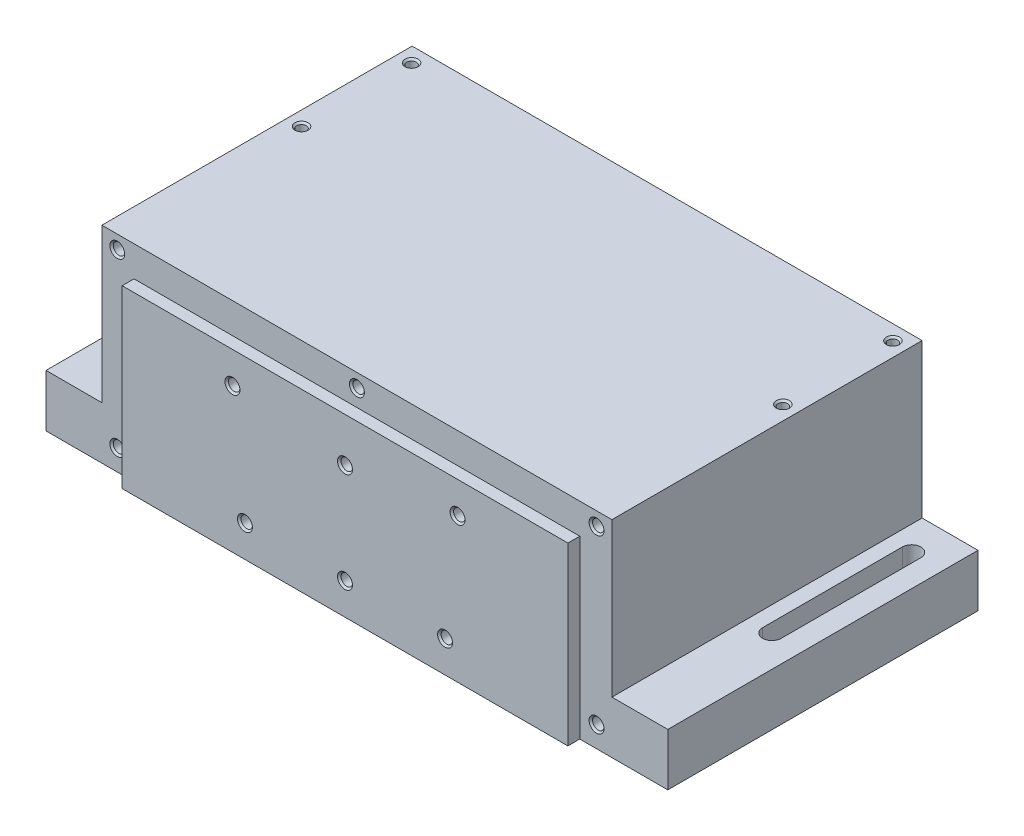
from build123d import *

# Parameters (mm, degrees)
BOSS_EXTRUDE1_DEPTH              = 50.8
F_6_32_TAPPED_HOLE1_AT_2_COUNT   = 2
F_6_32_TAPPED_HOLE1_AT_2_PITCH   = 40.005
F_6_32_TAPPED_HOLE1_AT_3_COUNT   = 2
F_6_32_TAPPED_HOLE1_AT_3_PITCH   = 179.52019402
F_6_32_TAPPED_HOLE1_AT_4_COUNT   = 2
F_6_32_TAPPED_HOLE1_AT_4_PITCH   = 175.006
BOSS_EXTRUDE2_DEPTH              = 61.976
CUT_EXTRUDE2_DEPTH               = 20.05
F_8_32_TAPPED_HOLE1_AT_2_COUNT   = 2
F_8_32_TAPPED_HOLE1_AT_2_PITCH   = 62.357
F_8_32_TAPPED_HOLE1_AT_3_COUNT   = 2
F_8_32_TAPPED_HOLE1_AT_3_PITCH   = 185.065844998
F_8_32_TAPPED_HOLE1_AT_4_COUNT   = 2
F_8_32_TAPPED_HOLE1_AT_4_PITCH   = 174.244
F_8_32_TAPPED_HOLE1_AT_5_COUNT   = 2
F_8_32_TAPPED_HOLE1_AT_5_PITCH   = 87.122
SKETCH13_W                       = 162.052
SKETCH13_H                       = 63.881
BOSS_EXTRUDE4_DEPTH              = 4.318
F_8_32_TAPPED_HOLE2_AT_2_COUNT   = 2
F_8_32_TAPPED_HOLE2_AT_2_PITCH   = 41.171214069
F_8_32_TAPPED_HOLE2_AT_3_COUNT   = 2
F_8_32_TAPPED_HOLE2_AT_3_PITCH   = 87.455597175
F_8_32_TAPPED_HOLE2_AT_4_COUNT   = 2
F_8_32_TAPPED_HOLE2_AT_4_PITCH   = 81.8388
F_8_32_TAPPED_HOLE2_AT_5_COUNT   = 2
F_8_32_TAPPED_HOLE2_AT_5_PITCH   = 57.868770444
F_8_32_TAPPED_HOLE2_AT_6_COUNT   = 2
F_8_32_TAPPED_HOLE2_AT_6_PITCH   = 41.171214069
CUT_EXTRUDE3_DEPTH               = 3.54
F_1_4_20_TAPPED_HOLE1_AT_2_COUNT = 2
F_1_4_20_TAPPED_HOLE1_AT_2_PITCH = 50.8


with BuildPart() as part:
    # Sketch1 → Boss-Extrude1 (new body)
    with BuildSketch(Plane.XY):
        Polygon((-92.71, 2.54), (92.71, 2.54), (92.71, 0), (113.03, 0), (113.03, 19.05), (92.71, 19.05), (92.71, 74.93), (-92.71, 74.93), (-92.71, 19.05), (-113.03, 19.05), (-113.03, 0), (-92.71, 0), align=None)
    extrude(amount=-BOSS_EXTRUDE1_DEPTH)

    # Sketch3 → #6-32 Tapped Hole1 (revolve, cut)
    with BuildSketch(Plane(origin=(-87.503, 74.93, -45.4025), x_dir=(0, 0, 1), z_dir=(1, 0, 0))):
        Polygon((0, 0), (0, 14.42709403), (1.35255, 13.6144), (1.35255, 9.652), (1.7526, 9.652), (1.7526, 0.635), (2.3876, 0), align=None)
    f_6_32_tapped_hole1 = revolve(axis=Axis((-87.503, 81.28, -45.4025), (0, -1, 0)), mode=Mode.SUBTRACT)

    # #6-32 Tapped Hole1 at 2: #6-32 Tapped Hole1 ×2
    with Locations(*[(0, 0, i * F_6_32_TAPPED_HOLE1_AT_2_PITCH) for i in range(1, F_6_32_TAPPED_HOLE1_AT_2_COUNT)]):
        add(f_6_32_tapped_hole1, mode=Mode.SUBTRACT)

    # #6-32 Tapped Hole1 at 3: #6-32 Tapped Hole1 ×2
    with Locations(*[Vector(0.974854116, 0, 0.22284401) * (i * F_6_32_TAPPED_HOLE1_AT_3_PITCH) for i in range(1, F_6_32_TAPPED_HOLE1_AT_3_COUNT)]):
        add(f_6_32_tapped_hole1, mode=Mode.SUBTRACT)

    # #6-32 Tapped Hole1 at 4: #6-32 Tapped Hole1 ×2
    with Locations(*[(i * F_6_32_TAPPED_HOLE1_AT_4_PITCH, 0, 0) for i in range(1, F_6_32_TAPPED_HOLE1_AT_4_COUNT)]):
        add(f_6_32_tapped_hole1, mode=Mode.SUBTRACT)

    # Sketch5 → Boss-Extrude2 (add)
    with BuildSketch(Plane.XY):
        Polygon((92.71, 74.93), (-92.71, 74.93), (-92.71, 19.05), (-113.03, 19.05), (-113.03, 0), (113.03, 0), (113.03, 19.05), (92.71, 19.05), align=None)
    extrude(amount=BOSS_EXTRUDE2_DEPTH)

    # Sketch16 → Cut-Extrude2 (cut, through all)
    with BuildSketch(Plane(origin=(0, 19.05, 0), x_dir=(1, 0, 0), z_dir=(0, 1, 0))):
        with BuildLine():
            Line((-104.9782, 38.1), (-104.9782, -12.7))
            ThreePointArc((-104.9782, -12.7), (-101.6, -16.0782), (-98.2218, -12.7))
            Line((-98.2218, -12.7), (-98.2218, 38.1))
            ThreePointArc((-98.2218, 38.1), (-101.6, 41.4782), (-104.9782, 38.1))
        make_face()
        with BuildLine():
            Line((104.9782, 38.1), (104.9782, -12.7))
            ThreePointArc((104.9782, -12.7), (101.6, -16.0782), (98.2218, -12.7))
            Line((98.2218, -12.7), (98.2218, 38.1))
            ThreePointArc((98.2218, 38.1), (101.6, 41.4782), (104.9782, 38.1))
        make_face()
    extrude(amount=-CUT_EXTRUDE2_DEPTH, mode=Mode.SUBTRACT)

    # Sketch11 → #8-32 Tapped Hole1 (revolve, cut)
    with BuildSketch(Plane(origin=(-87.122, 69.977, 61.976), x_dir=(0, -1, 0), z_dir=(1, 0, 0))):
        Polygon((0, 0), (0, 17.700206461), (1.7272, 16.6624), (1.7272, 12.7), (2.0828, 12.7), (2.0828, 0.635), (2.7178, 0), align=None)
    f_8_32_tapped_hole1 = revolve(axis=Axis((-87.122, 69.977, 68.326), (0, 0, -1)), mode=Mode.SUBTRACT)

    # #8-32 Tapped Hole1 at 2: #8-32 Tapped Hole1 ×2
    with Locations(*[(0, -i * F_8_32_TAPPED_HOLE1_AT_2_PITCH, 0) for i in range(1, F_8_32_TAPPED_HOLE1_AT_2_COUNT)]):
        add(f_8_32_tapped_hole1, mode=Mode.SUBTRACT)

    # #8-32 Tapped Hole1 at 3: #8-32 Tapped Hole1 ×2
    with Locations(*[Vector(0.941524353, -0.33694494, 0) * (i * F_8_32_TAPPED_HOLE1_AT_3_PITCH) for i in range(1, F_8_32_TAPPED_HOLE1_AT_3_COUNT)]):
        add(f_8_32_tapped_hole1, mode=Mode.SUBTRACT)

    # #8-32 Tapped Hole1 at 4: #8-32 Tapped Hole1 ×2
    with Locations(*[(i * F_8_32_TAPPED_HOLE1_AT_4_PITCH, 0, 0) for i in range(1, F_8_32_TAPPED_HOLE1_AT_4_COUNT)]):
        add(f_8_32_tapped_hole1, mode=Mode.SUBTRACT)

    # #8-32 Tapped Hole1 at 5: #8-32 Tapped Hole1 ×2
    with Locations(*[(i * F_8_32_TAPPED_HOLE1_AT_5_PITCH, 0, 0) for i in range(1, F_8_32_TAPPED_HOLE1_AT_5_COUNT)]):
        add(f_8_32_tapped_hole1, mode=Mode.SUBTRACT)

    # Sketch13 → Boss-Extrude4 (add)
    with BuildSketch(Plane.XY.offset(61.976)):
        with Locations((0, 31.9405)):
            Rectangle(SKETCH13_W, SKETCH13_H)
    extrude(amount=BOSS_EXTRUDE4_DEPTH)

    # Sketch7 → #8-32 Tapped Hole2 (revolve, cut)
    with BuildSketch(Plane(origin=(-40.9194, 52.4002, 66.294), x_dir=(0, -1, 0), z_dir=(1, 0, 0))):
        Polygon((0, 0), (0, 17.700206461), (1.7272, 16.6624), (1.7272, 12.7), (2.0828, 12.7), (2.0828, 0.635), (2.7178, 0), align=None)
    f_8_32_tapped_hole2 = revolve(axis=Axis((-40.9194, 52.4002, 72.644), (0, 0, -1)), mode=Mode.SUBTRACT)

    # #8-32 Tapped Hole2 at 2: #8-32 Tapped Hole2 ×2
    with Locations(*[Vector(0.110431526, -0.993883735, 0) * (i * F_8_32_TAPPED_HOLE2_AT_2_PITCH) for i in range(1, F_8_32_TAPPED_HOLE2_AT_2_COUNT)]):
        add(f_8_32_tapped_hole2, mode=Mode.SUBTRACT)

    # #8-32 Tapped Hole2 at 3: #8-32 Tapped Hole2 ×2
    with Locations(*[Vector(0.883787916, -0.46788772, 0) * (i * F_8_32_TAPPED_HOLE2_AT_3_PITCH) for i in range(1, F_8_32_TAPPED_HOLE2_AT_3_COUNT)]):
        add(f_8_32_tapped_hole2, mode=Mode.SUBTRACT)

    # #8-32 Tapped Hole2 at 4: #8-32 Tapped Hole2 ×2
    with Locations(*[(i * F_8_32_TAPPED_HOLE2_AT_4_PITCH, 0, 0) for i in range(1, F_8_32_TAPPED_HOLE2_AT_4_COUNT)]):
        add(f_8_32_tapped_hole2, mode=Mode.SUBTRACT)

    # #8-32 Tapped Hole2 at 5: #8-32 Tapped Hole2 ×2
    with Locations(*[Vector(0.707106781, -0.707106781, 0) * (i * F_8_32_TAPPED_HOLE2_AT_5_PITCH) for i in range(1, F_8_32_TAPPED_HOLE2_AT_5_COUNT)]):
        add(f_8_32_tapped_hole2, mode=Mode.SUBTRACT)

    # #8-32 Tapped Hole2 at 6: #8-32 Tapped Hole2 ×2
    with Locations(*[Vector(0.993883735, -0.110431526, 0) * (i * F_8_32_TAPPED_HOLE2_AT_6_PITCH) for i in range(1, F_8_32_TAPPED_HOLE2_AT_6_COUNT)]):
        add(f_8_32_tapped_hole2, mode=Mode.SUBTRACT)

    # Sketch17 → Cut-Extrude3 (cut, through all)
    with BuildSketch(Plane.XZ.offset(-2.54)):
        with BuildLine():
            Line((-92.71, 0), (92.71, 0))
            Line((92.71, 0), (92.71, 49.403))
            ThreePointArc((92.71, 49.403), (89.920192091, 56.138192091), (83.185, 58.928))
            Line((83.185, 58.928), (-83.185, 58.928))
            ThreePointArc((-83.185, 58.928), (-89.920192091, 56.138192091), (-92.71, 49.403))
            Line((-92.71, 49.403), (-92.71, 0))
        make_face()
    extrude(amount=CUT_EXTRUDE3_DEPTH, mode=Mode.SUBTRACT)

    # Sketch18 → 1/4-20 Tapped Hole1 (revolve, cut)
    with BuildSketch(Plane(origin=(25.4, 38.1, -50.8), x_dir=(0, 1, 0), z_dir=(1, 0, 0))):
        Polygon((0, 0), (0, 20.583816902), (2.5527, 19.05), (2.5527, 12.7), (3.175, 12.7), (3.175, 0.762), (3.937, 0), align=None)
    f_1_4_20_tapped_hole1 = revolve(axis=Axis((25.4, 38.1, -57.15), (0, 0, 1)), mode=Mode.SUBTRACT)

    # 1/4-20 Tapped Hole1 at 2: 1/4-20 Tapped Hole1 ×2
    with Locations(*[(-i * F_1_4_20_TAPPED_HOLE1_AT_2_PITCH, 0, 0) for i in range(1, F_1_4_20_TAPPED_HOLE1_AT_2_COUNT)]):
        add(f_1_4_20_tapped_hole1, mode=Mode.SUBTRACT)


solid = part.part
